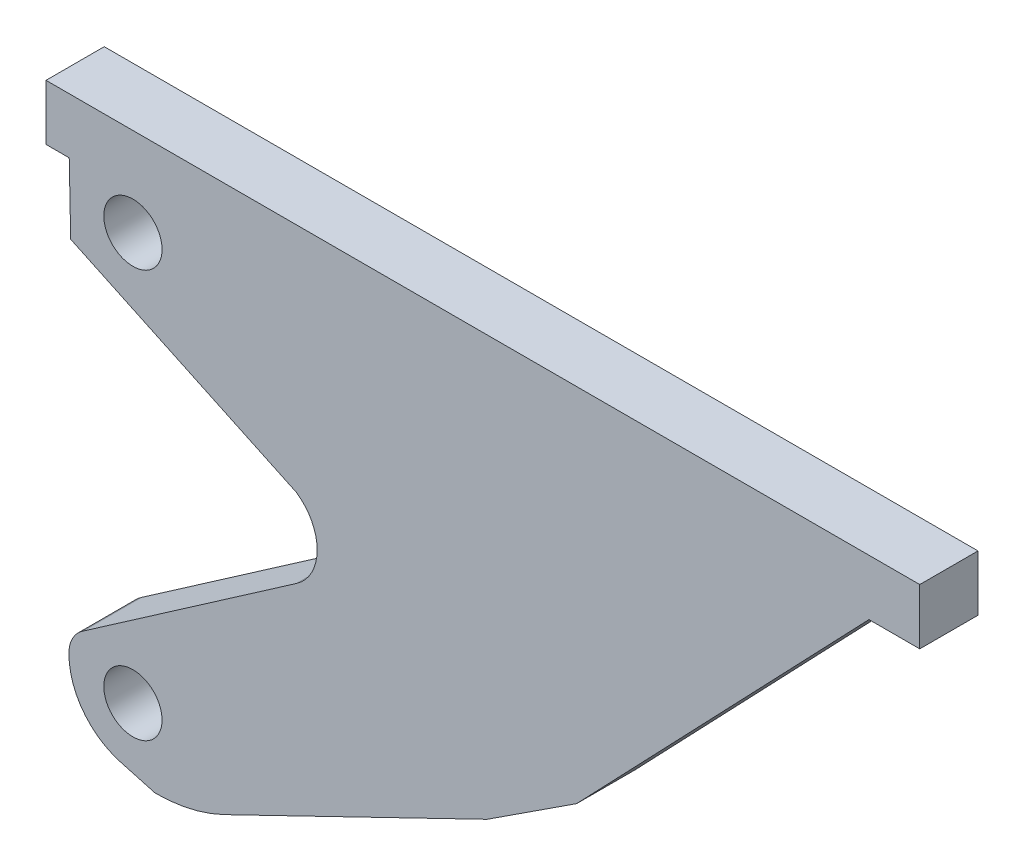
from build123d import *

# Parameters (mm, degrees)
SZKIC3_R                    = 10
DODANIE_WYCI_GNI_CIE2_DEPTH = 20


with BuildPart() as part:
    # Szkic3 → Dodanie-wyciągnięcie2 (new body)
    with BuildSketch(Plane.XY):
        with BuildLine():
            Line((12.67810929, 42.488794767), (86.036422739, 93.344089821))
            ThreePointArc((86.036422739, 93.344089821), (93.107358396, 106.849857247), (86.036422739, 120.355624672))
            Line((86.036422739, 120.355624672), (8.481056429, 156.898555423))
            Line((8.481056429, 156.898555423), (7.976636035, 180.8633929))
            Line((7.976636035, 180.8633929), (0, 180.8633929))
            Line((0, 180.8633929), (0, 199.930223275))
            Line((0, 199.930223275), (300, 200))
            Line((300, 200), (300, 180.8633929))
            Line((300, 180.8633929), (282.564213809, 180.8633929))
            Line((282.564213809, 180.8633929), (182.180079392, 75.935133422))
            Line((182.180079392, 75.935133422), (151.439346205, 55.907468715))
            Line((151.439346205, 55.907468715), (61.168077446, 12.167426414))
            ThreePointArc((61.168077446, 12.167426414), (49.626578665, 8.105505852), (37.468922524, 6.72826588))
            Line((37.468922524, 6.72826588), (25.574803596, 10.020549368))
            ThreePointArc((25.574803596, 10.020549368), (12.6494554, 18.873421693), (7.881217502, 33.796621141))
            ThreePointArc((7.881217502, 33.796621141), (9.209095866, 38.733514905), (12.67810929, 42.488794767))
        make_face()
        with Locations((29.845610796, 29.622773701)):
            Circle(SZKIC3_R, mode=Mode.SUBTRACT)
        with Locations((29.845610796, 169.541616803)):
            Circle(SZKIC3_R, mode=Mode.SUBTRACT)
    extrude(amount=DODANIE_WYCI_GNI_CIE2_DEPTH)


solid = part.part
